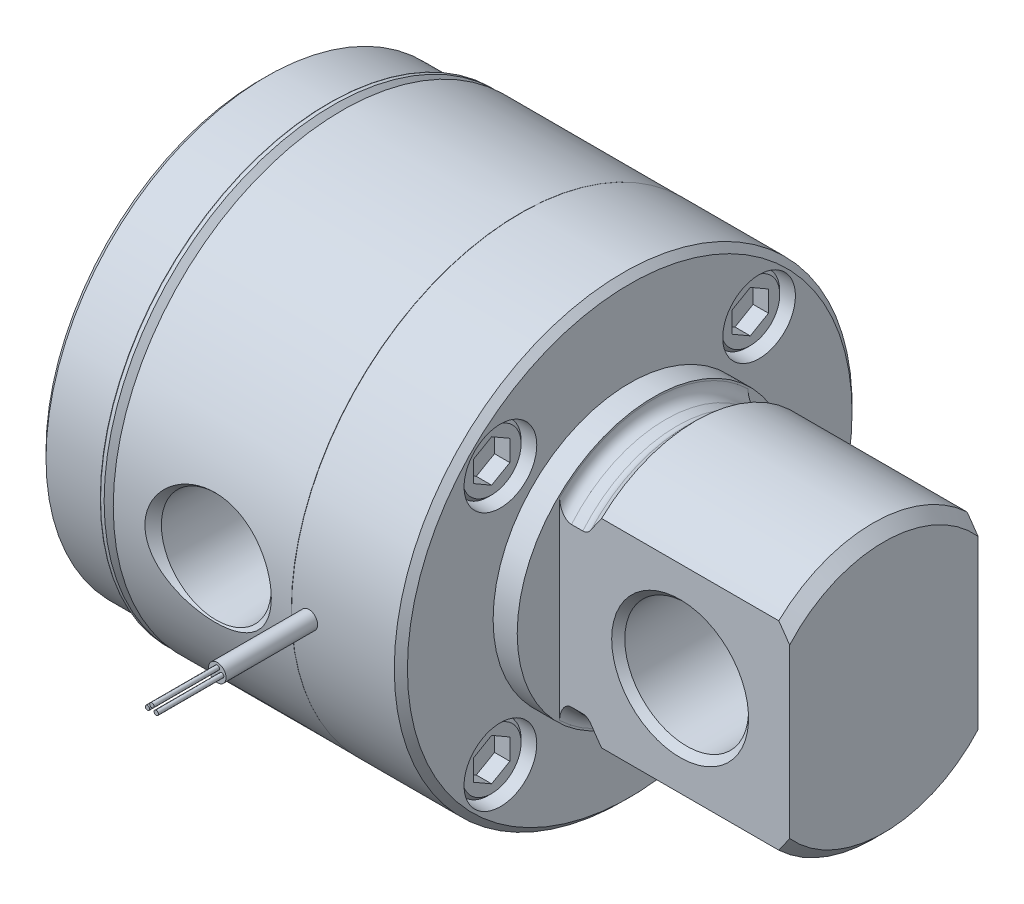
from build123d import *

# Parameters (mm, degrees)
HOLE1_D              = 8.4328
HOLE1_DEPTH          = 5.08
LPATTERN1_COUNT      = 2
LPATTERN1_PITCH      = 29.994055444
LPATTERN1_COUNT_DIR2 = 2
LPATTERN1_PITCH_DIR2 = 29.994055444
LPATTERN2_COUNT      = 2
LPATTERN2_PITCH      = 29.994055444
LPATTERN2_COUNT_DIR2 = 2
LPATTERN2_PITCH_DIR2 = 29.994055444
CUT_EXTRUDE1_DEPTH   = 1.778
LPATTERN3_COUNT      = 2
LPATTERN3_PITCH      = 29.994055444
LPATTERN3_COUNT_DIR2 = 2
LPATTERN3_PITCH_DIR2 = 29.994055444
SKETCH10_W           = 1.016
SKETCH10_H           = 13.2715
SKETCH11_W           = 0.254
SKETCH11_H           = 7.583714286
SKETCH12_W           = 0.254
SKETCH12_H           = 7.583714286
SKETCH13_W           = 7.583714286
SKETCH13_H           = 0.254
SKETCH17_W           = 53.086
SKETCH17_H           = 106.172
SKETCH17_W_2         = 21.844
SKETCH17_H_2         = 53.086
CUT_EXTRUDE2_DEPTH   = 29.464


with BuildPart() as part:
    # Sketch1 → Revolve1 (revolve)
    with BuildSketch(Plane.XY):
        Polygon((-42.8752, 0), (-42.8752, 24.8158), (-42.1132, 25.5778), (-35.4838, 25.5778), (-34.417, 24.511), (-33.3502, 24.511), (-33.3502, 26.543), (-12.7127, 26.5303), (-12.6746, 26.543), (-0.762, 26.543), (0, 25.781), (0, 0), align=None)
    revolve(axis=Axis((0, 0, 0), (-1, 0, 0)))

    # Sketch2 → Revolve2 (revolve)
    with BuildSketch(Plane.XY):
        with BuildLine():
            Line((-34.93160107, 26.318757951), (-32.800553898, 24.18771078))
            Line((-32.800553898, 24.18771078), (-32.477264678, 24.511))
            Line((-32.477264678, 24.511), (-34.458464678, 26.4922))
            Line((-34.458464678, 26.4922), (-34.859759021, 26.4922))
            ThreePointArc((-34.859759021, 26.4922), (-34.953625181, 26.429480637), (-34.93160107, 26.318757951))
        make_face()
    revolve(axis=Axis((-34.458464678, 0, 0), (-1, 0, 0)))

    # Hole1
    with Locations(Plane(origin=(0, 0, 0), x_dir=(0, 0, -1), z_dir=(1, 0, 0))):
        with Locations((-14.997027722, 14.997027722)):
            hole1 = Hole(HOLE1_D / 2, depth=HOLE1_DEPTH)

    # LPattern1: Hole1 2 × 2
    with Locations(*[(0, -j * LPATTERN1_PITCH_DIR2, -i * LPATTERN1_PITCH) for i in range(LPATTERN1_COUNT) for j in range(LPATTERN1_COUNT_DIR2) if (i, j) != (0, 0)]):
        add(hole1, mode=Mode.SUBTRACT)

    # Sketch6 → Revolve3 (revolve)
    with BuildSketch(Plane(origin=(0, 0, 0), x_dir=(1, 0, 0), z_dir=(0, -0.7071067811865477, 0.7071067811865475))):
        Polygon((-5.08, 21.209), (-5.08, 25.00376), (-1.397, 25.00376), (-1.016, 24.62276), (-1.016, 21.209), align=None)
    revolve3 = revolve(axis=Axis((-1.016, 14.997027722, 14.997027722), (-1, 0, 0)))

    # LPattern2: Revolve3 2 × 2
    with Locations(*[(0, -j * LPATTERN2_PITCH_DIR2, -i * LPATTERN2_PITCH) for i in range(LPATTERN2_COUNT) for j in range(LPATTERN2_COUNT_DIR2) if (i, j) != (0, 0)]):
        add(revolve3)

    # Sketch8 → Cut-Extrude1 (cut)
    with BuildSketch(Plane(origin=(-1.016, 0, 0), x_dir=(0, 0, -1), z_dir=(1, 0, 0))):
        Polygon((-17.105227722, 16.21419756), (-17.105227722, 13.779857885), (-14.997027722, 12.562688047), (-12.888827722, 13.779857885), (-12.888827722, 16.21419756), (-14.997027722, 17.431367397), align=None)
    cut_extrude1 = extrude(amount=-CUT_EXTRUDE1_DEPTH, mode=Mode.SUBTRACT)

    # LPattern3: Cut-Extrude1 2 × 2
    with Locations(*[(0, -j * LPATTERN3_PITCH_DIR2, -i * LPATTERN3_PITCH) for i in range(LPATTERN3_COUNT) for j in range(LPATTERN3_COUNT_DIR2) if (i, j) != (0, 0)]):
        add(cut_extrude1, mode=Mode.SUBTRACT)

    # Sketch10 → Revolve4 (revolve)
    with BuildSketch(Plane(origin=(0, 0, 0), x_dir=(1, 0, 0), z_dir=(0, 1, 0))):
        with Locations((-10.16, -30.52445)):
            Rectangle(SKETCH10_W, SKETCH10_H)
    revolve(axis=Axis((-10.668, 0, 37.1602), (0, 0, -1)))

    # Sketch11 → Revolve5 (revolve)
    with BuildSketch(Plane(origin=(0, 0, 0), x_dir=(1, 0, 0), z_dir=(0, 1, 0))):
        with Locations((-11.049, -40.952057143)):
            Rectangle(SKETCH11_W, SKETCH11_H)
    revolve(axis=Axis((-11.176, 0, 44.743914286), (0, 0, -1)))

    # Sketch12 → Revolve6 (revolve)
    with BuildSketch(Plane(origin=(0, 0, 0), x_dir=(1, 0, 0), z_dir=(0, 1, 0))):
        with Locations((-10.033, -40.952057143)):
            Rectangle(SKETCH12_W, SKETCH12_H)
    revolve(axis=Axis((-10.16, 0, 44.743914286), (0, 0, -1)))

    # Sketch13 → Revolve7 (revolve)
    with BuildSketch(Plane(origin=(-10.668, 0, 0), x_dir=(0, 0, -1), z_dir=(1, 0, 0))):
        with Locations((-40.952057143, 0.635)):
            Rectangle(SKETCH13_W, SKETCH13_H)
    revolve(axis=Axis((-10.668, 0.508, 37.1602), (0, 0, 1)))

    # Sketch14 → Cut-Revolve1 (revolve, cut)
    with BuildSketch(Plane.XY):
        Polygon((-42.8752, 0), (-42.8752, 13.1699), (-33.7058, 13.1699), (-33.7058, 3.81), (-12.7, 3.81), (-12.7, 12.7), (-5.08, 12.7), (-5.08, 0), align=None)
    revolve(axis=Axis((-5.08, 0, 0), (-1, 0, 0)), mode=Mode.SUBTRACT)

    # Sketch15 → Cut-Revolve2 (revolve, cut)
    with BuildSketch(Plane(origin=(0, 0, 0), x_dir=(1, 0, 0), z_dir=(0, 1, 0))):
        Polygon((-22.352, 0), (-16.671585745, -3.279588699), (-16.671585745, -3.429), (-15.979865896, -25.585630358), (-15.022496254, -26.543), (-22.352, -26.543), align=None)
    revolve(axis=Axis((-22.352, 0, 26.543), (0, 0, -1)), mode=Mode.SUBTRACT)

    # Sketch16 → Revolve8 (revolve)
    with BuildSketch(Plane.XY):
        with BuildLine():
            Line((0, 0), (0, 15.84325))
            Line((0, 15.84325), (2.794, 15.84325))
            Line((2.794, 15.84325), (2.794, 15.6337))
            ThreePointArc((2.794, 15.6337), (3.195732339, 14.663832339), (4.1656, 14.2621))
            Line((4.1656, 14.2621), (5.477064678, 14.2621))
            ThreePointArc((5.477064678, 14.2621), (6.001953274, 14.366506833), (6.446932339, 14.663832339))
            Line((6.446932339, 14.663832339), (7.6581, 15.875))
            Line((7.6581, 15.875), (28.20416, 15.875))
            Line((28.20416, 15.875), (29.464, 14.61516))
            Line((29.464, 14.61516), (29.464, 0))
            Line((29.464, 0), (0, 0))
        make_face()
    revolve(axis=Axis((29.464, 0, 0), (-1, 0, 0)))

    # Sketch17 → Cut-Extrude2 (cut)
    with BuildSketch(Plane(origin=(2.794, 0, 0), x_dir=(0, 0, -1), z_dir=(1, 0, 0))):
        Rectangle(SKETCH17_W, SKETCH17_H)
        Rectangle(SKETCH17_W_2, SKETCH17_H_2, mode=Mode.SUBTRACT)
    extrude(amount=CUT_EXTRUDE2_DEPTH, mode=Mode.SUBTRACT)

    # Sketch18 → Cut-Revolve3 (revolve, cut)
    with BuildSketch(Plane(origin=(0, 0, 0), x_dir=(1, 0, 0), z_dir=(0, 1, 0))):
        Polygon((16.764, 10.922), (24.7015, 10.922), (23.9395, 10.16), (23.9395, -10.16), (24.7015, -10.922), (16.764, -10.922), align=None)
    revolve(axis=Axis((16.764, 0, 10.922), (0, 0, -1)), mode=Mode.SUBTRACT)


solid = part.part
